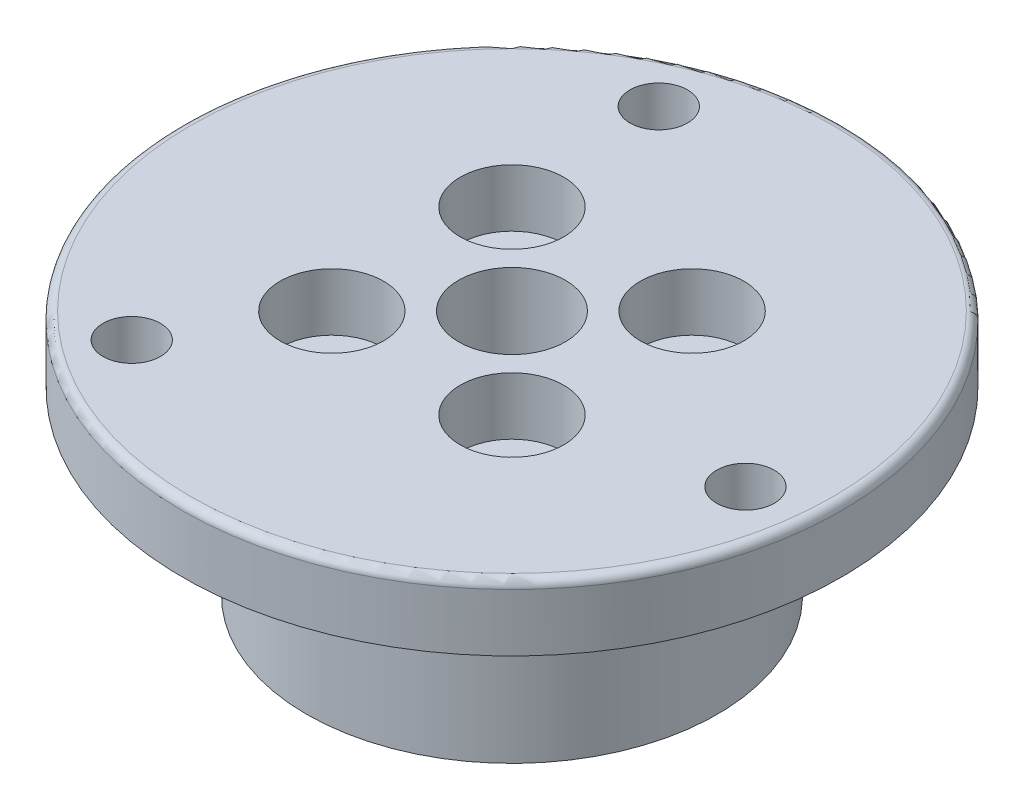
from build123d import *

# Parameters (mm, degrees)
SKETCH1_R      = 20.05
SKETCH1_R_2    = 3.25
SKETCH1_R_3    = 1.75
EXTRUDE1_DEPTH = 15
SKETCH7_R      = 3.15
EXTRUDE4_DEPTH = 3.5
SKETCH8_R      = 20.05
SKETCH8_R_2    = 12.5
EXTRUDE5_DEPTH = 11
FILLET_1_R     = 0.5


with BuildPart() as part:
    # Sketch1 → Extrude1 (new body)
    with BuildSketch(Plane(origin=(0, 0, 0), x_dir=(1, 0, 0), z_dir=(0, 1, 0))):
        Circle(SKETCH1_R)
        Circle(SKETCH1_R_2, mode=Mode.SUBTRACT)
        with Locations((5.480077554, 5.480077554)):
            Circle(SKETCH1_R_3, mode=Mode.SUBTRACT)
        with Locations((5.480077554, -5.480077554)):
            Circle(SKETCH1_R_3, mode=Mode.SUBTRACT)
        with Locations((-5.480077554, -5.480077554)):
            Circle(SKETCH1_R_3, mode=Mode.SUBTRACT)
        with Locations((-5.480077554, 5.480077554)):
            Circle(SKETCH1_R_3, mode=Mode.SUBTRACT)
        with Locations((-10.044563579, -13.090330115)):
            Circle(SKETCH1_R_3, mode=Mode.SUBTRACT)
        with Locations((-6.314276634, 15.244012286)):
            Circle(SKETCH1_R_3, mode=Mode.SUBTRACT)
        with Locations((16.358840213, -2.153682172)):
            Circle(SKETCH1_R_3, mode=Mode.SUBTRACT)
    extrude(amount=EXTRUDE1_DEPTH)

    # Sketch7 → Extrude4 (cut)
    with BuildSketch(Plane(origin=(0, 15, 0), x_dir=(1, 0, 0), z_dir=(0, 1, 0))):
        with Locations((-5.480077554, 5.480077554)):
            Circle(SKETCH7_R)
        with Locations((5.480077554, 5.480077554)):
            Circle(SKETCH7_R)
        with Locations((5.480077554, -5.480077554)):
            Circle(SKETCH7_R)
        with Locations((-5.480077554, -5.480077554)):
            Circle(SKETCH7_R)
    extrude(amount=-EXTRUDE4_DEPTH, mode=Mode.SUBTRACT)

    # Sketch8 → Extrude5 (cut)
    with BuildSketch(Plane.XZ):
        Circle(SKETCH8_R)
        Circle(SKETCH8_R_2, mode=Mode.SUBTRACT)
    extrude(amount=-EXTRUDE5_DEPTH, mode=Mode.SUBTRACT)

    # 圓角1
    fillet_1_edges = [part.edges().sort_by_distance(p)[0] for p in [
        (-20.05, 15, 0),
    ]]
    fillet(fillet_1_edges, radius=FILLET_1_R)


solid = part.part
